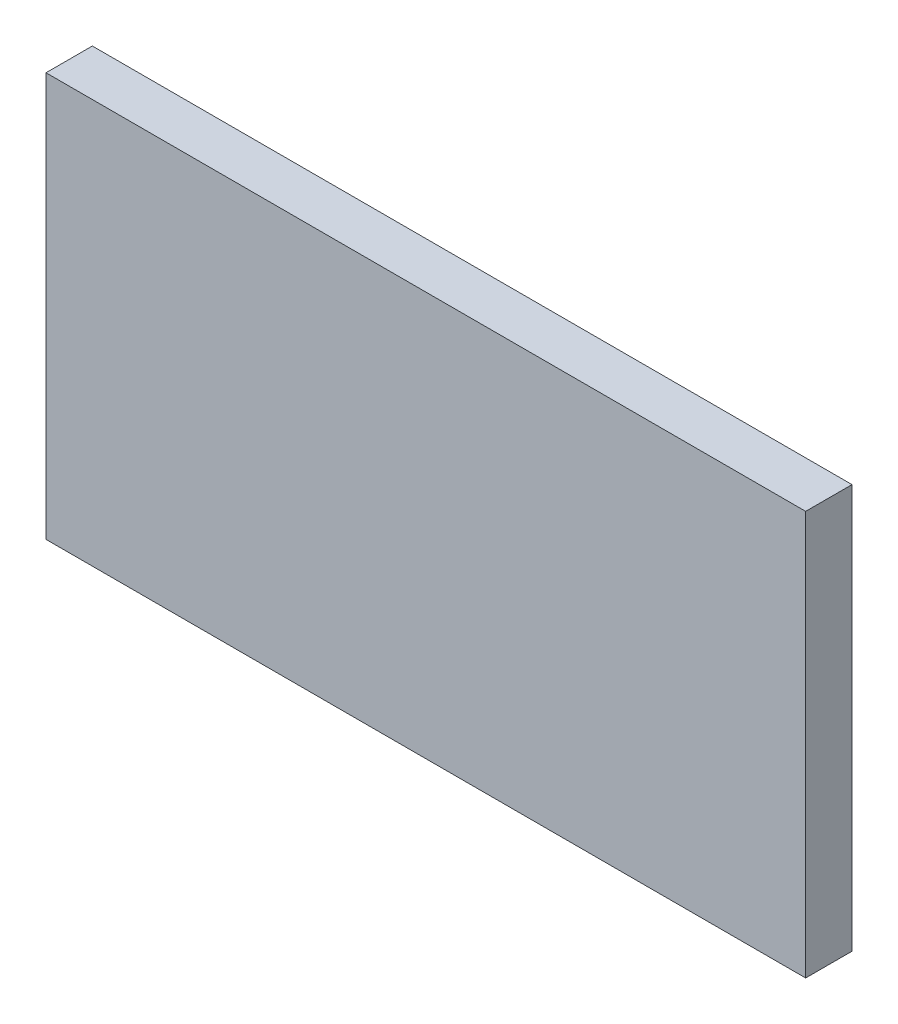
from build123d import *

# Parameters (mm, degrees)
ESQUISSE1_W        = 250
ESQUISSE1_H        = 133
BOSS_EXTRU_1_DEPTH = 15.25


with BuildPart() as part:
    # Esquisse1 → Boss.-Extru.1 (new body)
    with BuildSketch(Plane.XY):
        with Locations((0, 908.870969311)):
            Rectangle(ESQUISSE1_W, ESQUISSE1_H)
    extrude(amount=BOSS_EXTRU_1_DEPTH)


solid = part.part
